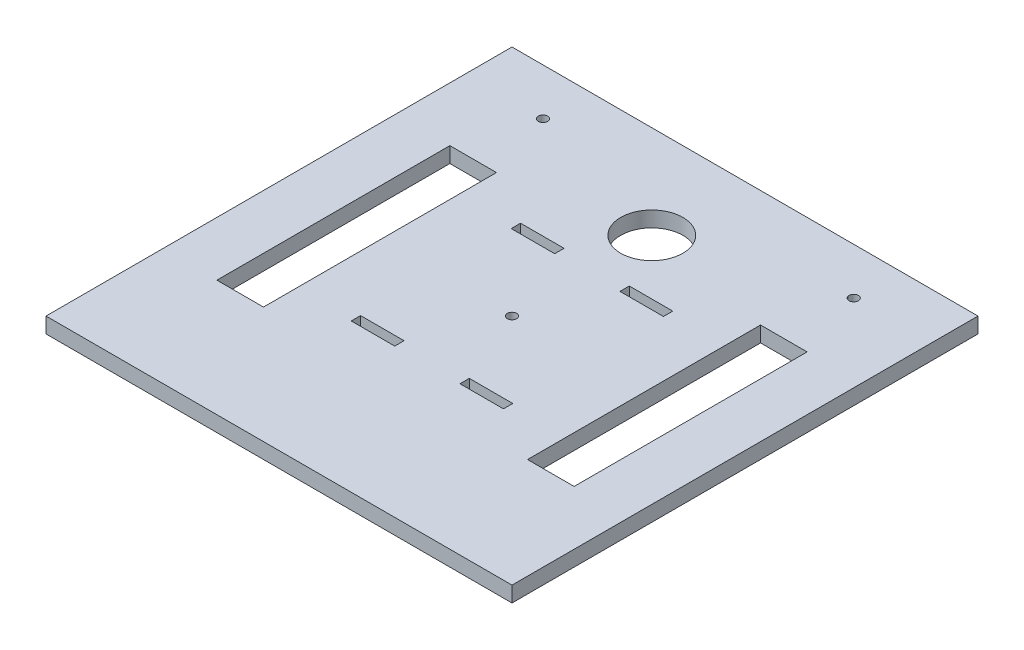
from build123d import *

# Parameters (mm, degrees)
SKETCH1_W           = 150
SKETCH1_H           = 150
SKETCH1_W_2         = 15
SKETCH1_H_2         = 75
BOSS_EXTRUDE1_DEPTH = 5
SKETCH2_R           = 1.5
SKETCH2_R_2         = 10
SKETCH2_W           = 14
SKETCH2_H           = 3
CUT_EXTRUDE1_DEPTH  = 5


with BuildPart() as part:
    # Sketch1 → Boss-Extrude1 (new body)
    with BuildSketch(Plane(origin=(0, 0, 0), x_dir=(1, 0, 0), z_dir=(0, 1, 0))):
        Rectangle(SKETCH1_W, SKETCH1_H)
        with Locations((-50, 0)):
            Rectangle(SKETCH1_W_2, SKETCH1_H_2, mode=Mode.SUBTRACT)
        with Locations((50, 0)):
            Rectangle(SKETCH1_W_2, SKETCH1_H_2, mode=Mode.SUBTRACT)
    extrude(amount=BOSS_EXTRUDE1_DEPTH)

    # Sketch2 → Cut-Extrude1 (cut)
    with BuildSketch(Plane(origin=(0, 5, 0), x_dir=(1, 0, 0), z_dir=(0, 1, 0))):
        with Locations((-50, 60)):
            Circle(SKETCH2_R)
        with Locations((50, 60)):
            Circle(SKETCH2_R)
        with Locations((0, 45)):
            Circle(SKETCH2_R_2)
        Circle(SKETCH2_R)
        with Locations((-17.5, 25.75)):
            Rectangle(SKETCH2_W, SKETCH2_H)
        with Locations((17.5, 25.75)):
            Rectangle(SKETCH2_W, SKETCH2_H)
        with Locations((-17.5, -25.75)):
            Rectangle(SKETCH2_W, SKETCH2_H)
        with Locations((17.5, -25.75)):
            Rectangle(SKETCH2_W, SKETCH2_H)
    extrude(amount=-CUT_EXTRUDE1_DEPTH, mode=Mode.SUBTRACT)


solid = part.part
